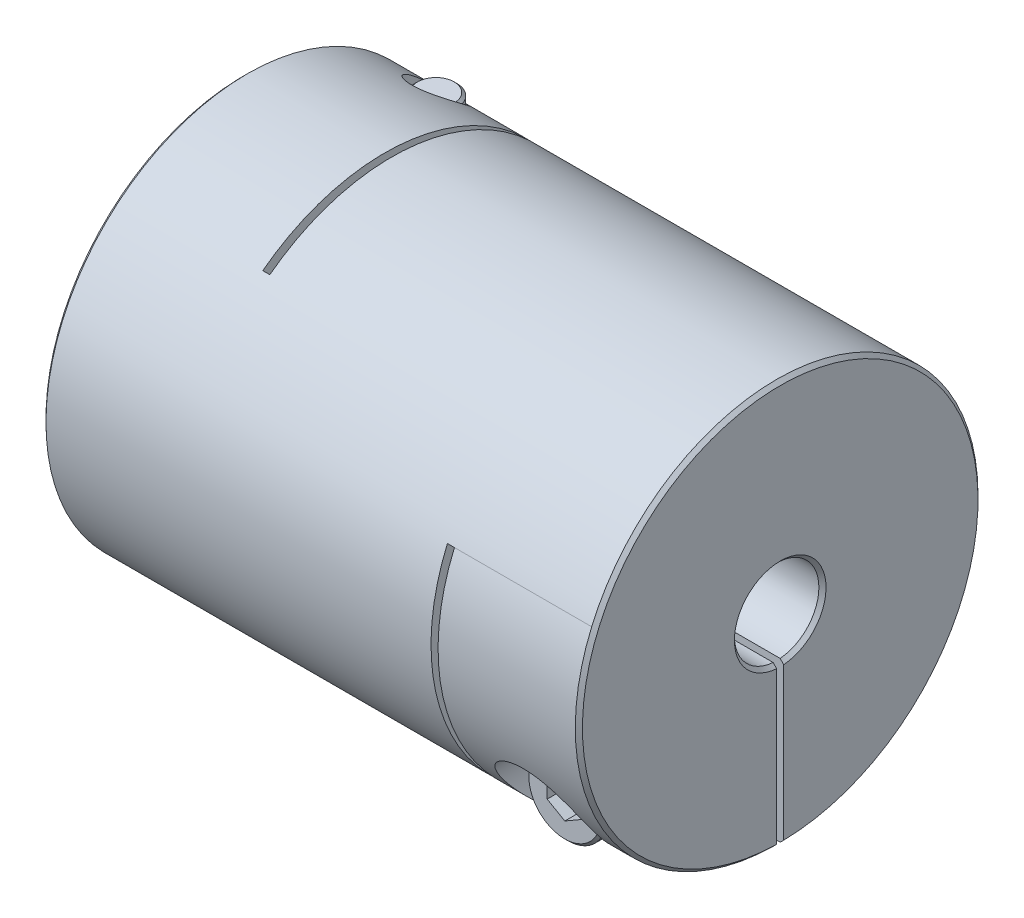
from build123d import *

# Parameters (mm, degrees)
SKETCH1_R                      = 14.3
BOSS_EXTRUDE1_DEPTH            = 19.05
SKETCH2_R                      = 3
CUT_EXTRUDE1_DEPTH             = 39.1
CHAMFER1_SIZE                  = 0.254
SKETCH4_W                      = 0.5
SKETCH4_H                      = 22.95
CUT_EXTRUDE2_DEPTH             = 29.6
SKETCH7_W                      = 0.5
SKETCH7_H                      = 19.95
CUT_EXTRUDE3_DEPTH             = 29.6
SKETCH8_W                      = 10
SKETCH8_H                      = 14.3
CUT_EXTRUDE5_DEPTH             = 0.25
SKETCH13_W                     = 10
SKETCH13_H                     = 14.3
CUT_EXTRUDE6_DEPTH             = 0.25
CBORE_FOR_M3_SHCS1_D           = 3.4
CBORE_FOR_M3_SHCS1_CBORE_D     = 6.5
CBORE_FOR_M3_SHCS1_CBORE_DEPTH = 7
CBORE_FOR_M3_SHCS2_D           = 3.4
CBORE_FOR_M3_SHCS2_CBORE_D     = 6.5
CBORE_FOR_M3_SHCS2_CBORE_DEPTH = 7
SKETCH16_R                     = 2.75
BOSS_EXTRUDE2_DEPTH            = 3
SKETCH17_R                     = 1.5
BOSS_EXTRUDE3_DEPTH            = 18.5
CHAMFER2_SIZE                  = 0.2
CUT_EXTRUDE7_DEPTH             = 1.5
CIRPATTERN1_COUNT              = 2
CIRPATTERN1_ANGLE              = 90


with BuildPart() as part:
    # Sketch1 → Boss-Extrude1 (new body, symmetric)
    with BuildSketch(Plane(origin=(0, 0, 0), x_dir=(0, 0, -1), z_dir=(1, 0, 0))):
        Circle(SKETCH1_R)
    extrude(amount=BOSS_EXTRUDE1_DEPTH, both=True)

    # Sketch2 → Cut-Extrude1 (cut, through all)
    with BuildSketch(Plane(origin=(19.05, 0, 0), x_dir=(0, 0, -1), z_dir=(1, 0, 0))):
        Circle(SKETCH2_R)
    extrude(amount=-CUT_EXTRUDE1_DEPTH, mode=Mode.SUBTRACT)

    # Chamfer1
    chamfer1_edges = [part.edges().sort_by_distance(p)[0] for p in [
        (-19.05, 0, 14.3),
        (19.05, 0, 14.3),
        (-19.05, 0, 3),
        (19.05, 0, 3),
    ]]
    chamfer(chamfer1_edges, length=CHAMFER1_SIZE)

    # Sketch4 → Cut-Extrude2 (cut, through all)
    with BuildSketch(Plane.XZ.offset(14.3)):
        with Locations((-8.8, -2.825)):
            Rectangle(SKETCH4_W, SKETCH4_H)
    extrude(amount=-CUT_EXTRUDE2_DEPTH, mode=Mode.SUBTRACT)

    # Sketch7 → Cut-Extrude3 (cut, through all)
    with BuildSketch(Plane(origin=(0, 0, -14.3), x_dir=(-1, 0, 0), z_dir=(0, 0, -1))):
        with Locations((-8.8, -4.325)):
            Rectangle(SKETCH7_W, SKETCH7_H)
    extrude(amount=-CUT_EXTRUDE3_DEPTH, mode=Mode.SUBTRACT)

    # Sketch8 → Cut-Extrude5 (cut, symmetric)
    with BuildSketch(Plane(origin=(0, 0, 0), x_dir=(1, 0, 0), z_dir=(0, 1, 0))):
        with Locations((-14.05, 7.15)):
            Rectangle(SKETCH8_W, SKETCH8_H)
    extrude(amount=CUT_EXTRUDE5_DEPTH, both=True, mode=Mode.SUBTRACT)

    # Sketch13 → Cut-Extrude6 (cut, symmetric)
    with BuildSketch(Plane.XY):
        with Locations((14.05, -7.15)):
            Rectangle(SKETCH13_W, SKETCH13_H)
    extrude(amount=CUT_EXTRUDE6_DEPTH, both=True, mode=Mode.SUBTRACT)

    # CBORE for M3 SHCS1 (through all)
    with Locations(Plane.XZ.offset(14.3)):
        with Locations((-14.05, -8.643689852)):
            CounterBoreHole(CBORE_FOR_M3_SHCS1_D / 2, CBORE_FOR_M3_SHCS1_CBORE_D / 2, CBORE_FOR_M3_SHCS1_CBORE_DEPTH)

    # CBORE for M3 SHCS2 (through all)
    with Locations(Plane.XY.offset(14.3)):
        with Locations((14.05, -8.643689852)):
            CounterBoreHole(CBORE_FOR_M3_SHCS2_D / 2, CBORE_FOR_M3_SHCS2_CBORE_D / 2, CBORE_FOR_M3_SHCS2_CBORE_DEPTH)


with BuildPart() as body_2:
    # Sketch16 → Boss-Extrude2 (new body)
    with BuildSketch(Plane.XY.offset(7.3)):
        with Locations((14.05, -8.643689852)):
            Circle(SKETCH16_R)
    extrude(amount=BOSS_EXTRUDE2_DEPTH)

    # Sketch17 → Boss-Extrude3 (add)
    with BuildSketch(Plane(origin=(0, 0, 7.3), x_dir=(-1, 0, 0), z_dir=(0, 0, -1))):
        with Locations(Location((-14.05, -8.643689852, 0), (0, 0, 180))):  # turned: the seam where the file's is
            Circle(SKETCH17_R)
    extrude(amount=BOSS_EXTRUDE3_DEPTH)

    # Chamfer2
    chamfer2_edges = [body_2.edges().sort_by_distance(p)[0] for p in [
        (11.3, -8.643689852, 7.3),
        (11.3, -8.643689852, 10.3),
        (12.55, -8.643689852, -11.2),
    ]]
    chamfer(chamfer2_edges, length=CHAMFER2_SIZE)

    # Sketch18 → Cut-Extrude7 (cut)
    with BuildSketch(Plane.XY.offset(10.3)):
        Polygon((14.05, -10.087065525), (15.3, -9.365377689), (15.3, -7.922002016), (14.05, -7.200314179), (12.8, -7.922002016), (12.8, -9.365377689), align=None)
    extrude(amount=-CUT_EXTRUDE7_DEPTH, mode=Mode.SUBTRACT)


with BuildPart() as body_3:
    # Mirror1: mirrored copy
    add(body_2.part.mirror(Plane(origin=(0, 0, 0), x_dir=(0, 0, 1), z_dir=(1, 0, 0))))


with BuildPart() as cirpattern1_1:
    # CirPattern1: pattern copy
    add(body_3.part.rotate(Axis((0, 0, 0), (1, 0, 0)), 1 * CIRPATTERN1_ANGLE / (CIRPATTERN1_COUNT - 1)))


solid = Compound([part.part, body_2.part, cirpattern1_1.part])
